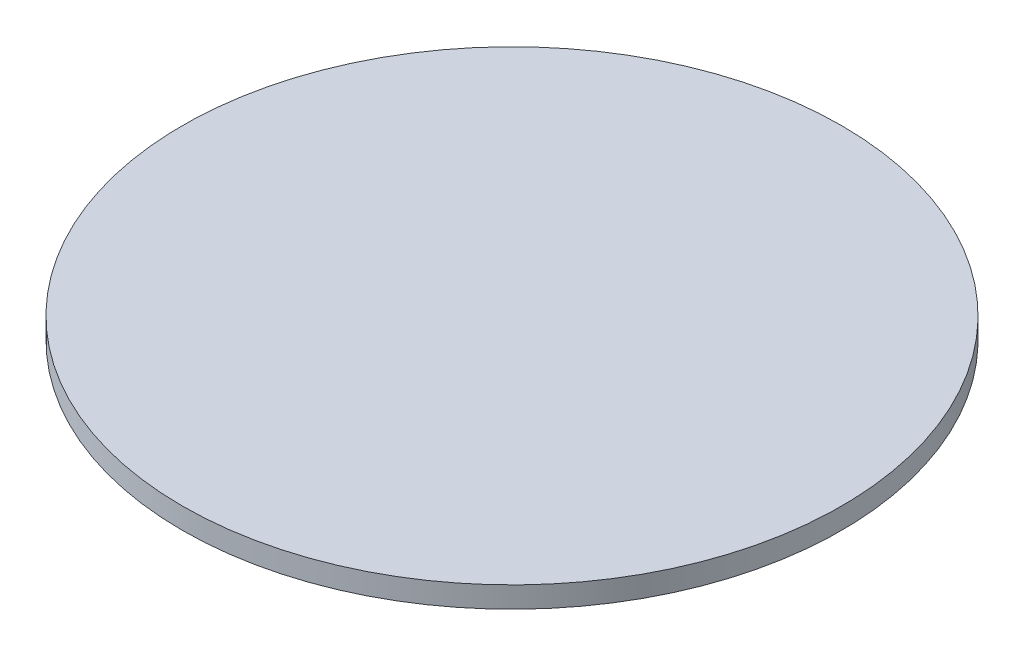
from build123d import *

# Parameters (mm, degrees)
SKETCH1_R           = 62.5
BOSS_EXTRUDE1_DEPTH = 4


with BuildPart() as part:
    # Sketch1 → Boss-Extrude1 (new body)
    with BuildSketch(Plane(origin=(0, 0, 0), x_dir=(1, 0, 0), z_dir=(0, 1, 0))):
        Circle(SKETCH1_R)
    extrude(amount=BOSS_EXTRUDE1_DEPTH)


solid = part.part
